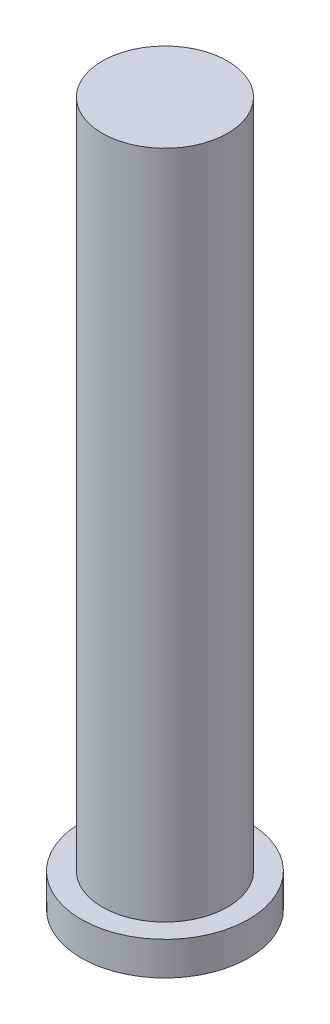
from build123d import *

# Parameters (mm, degrees)
SKETCH1_R           = 6.35
BOSS_EXTRUDE1_DEPTH = 2.54
SKETCH2_R           = 4.7498
BOSS_EXTRUDE2_DEPTH = 50.8


with BuildPart() as part:
    # Sketch1 → Boss-Extrude1 (new body)
    with BuildSketch(Plane(origin=(0, 0, 0), x_dir=(1, 0, 0), z_dir=(0, 1, 0))):
        Circle(SKETCH1_R)
    extrude(amount=BOSS_EXTRUDE1_DEPTH)

    # Sketch2 → Boss-Extrude2 (add)
    with BuildSketch(Plane(origin=(0, 2.54, 0), x_dir=(1, 0, 0), z_dir=(0, 1, 0))):
        Circle(SKETCH2_R)
    extrude(amount=BOSS_EXTRUDE2_DEPTH)


solid = part.part
